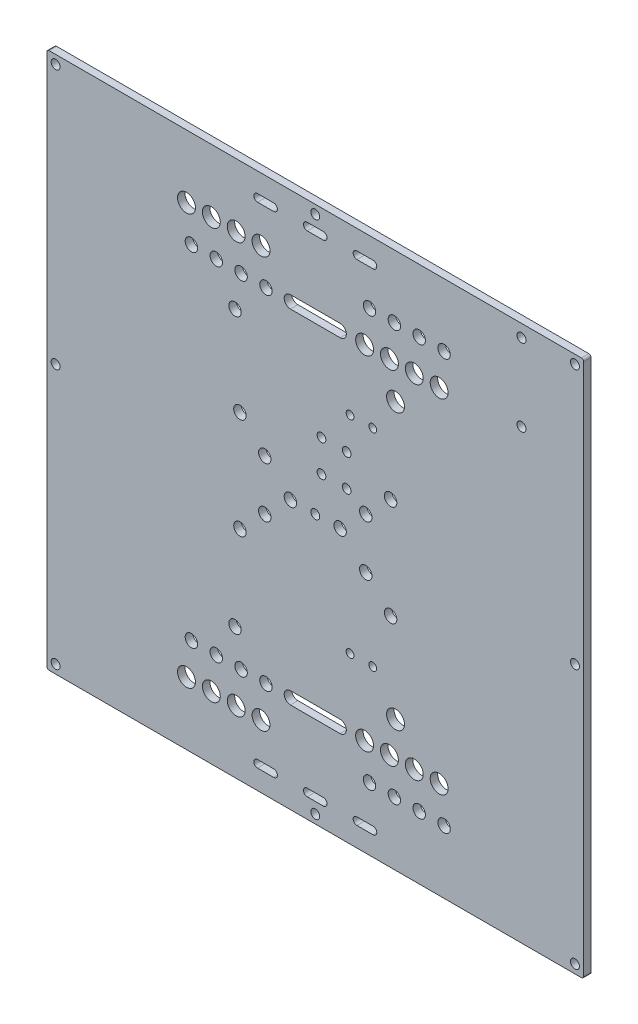
from build123d import *

# Parameters (mm, degrees)
SKETCH1_R           = 1.8
SKETCH1_R_2         = 2.5
SKETCH1_R_3         = 3.6
SKETCH1_R_4         = 1.57
SKETCH1_R_5         = 1.75
BOSS_EXTRUDE1_DEPTH = 3


with BuildPart() as part:
    # Sketch1 → Boss-Extrude1 (new body)
    with BuildSketch(Plane.XY):
        with BuildLine():
            Line((-107.125, -108), (107.125, -108))
            ThreePointArc((107.125, -108), (107.743718434, -107.743718434), (108, -107.125))
            Line((108, -107.125), (108, 107.125))
            ThreePointArc((108, 107.125), (107.743718434, 107.743718434), (107.125, 108))
            Line((107.125, 108), (-107.125, 108))
            ThreePointArc((-107.125, 108), (-107.743718434, 107.743718434), (-108, 107.125))
            Line((-108, 107.125), (-108, -107.125))
            ThreePointArc((-108, -107.125), (-107.743718434, -107.743718434), (-107.125, -108))
        make_face()
        with Locations((-104.5, -104.5)):
            Circle(SKETCH1_R, mode=Mode.SUBTRACT)
        with Locations((104.5, -104.5)):
            Circle(SKETCH1_R, mode=Mode.SUBTRACT)
        with Locations((-104.5, 104.5)):
            Circle(SKETCH1_R, mode=Mode.SUBTRACT)
        with Locations((104.5, 104.5)):
            Circle(SKETCH1_R, mode=Mode.SUBTRACT)
        with Locations((-49.85, -69)):
            Circle(SKETCH1_R_2, mode=Mode.SUBTRACT)
        with Locations((-39.85, -69)):
            Circle(SKETCH1_R_2, mode=Mode.SUBTRACT)
        with Locations((-29.85, -69)):
            Circle(SKETCH1_R_2, mode=Mode.SUBTRACT)
        with Locations((-19.855, -69)):
            Circle(SKETCH1_R_2, mode=Mode.SUBTRACT)
        with Locations((49.85, -69)):
            Circle(SKETCH1_R_3, mode=Mode.SUBTRACT)
        with Locations((39.85, -69)):
            Circle(SKETCH1_R_3, mode=Mode.SUBTRACT)
        with Locations((29.85, -69)):
            Circle(SKETCH1_R_3, mode=Mode.SUBTRACT)
        with Locations((19.855, -69)):
            Circle(SKETCH1_R_3, mode=Mode.SUBTRACT)
        with Locations((0, -104.5)):
            Circle(SKETCH1_R, mode=Mode.SUBTRACT)
        with Locations((0, 104.5)):
            Circle(SKETCH1_R, mode=Mode.SUBTRACT)
        with Locations((49.85, 69)):
            Circle(SKETCH1_R_3, mode=Mode.SUBTRACT)
        with Locations((39.85, 69)):
            Circle(SKETCH1_R_3, mode=Mode.SUBTRACT)
        with Locations((29.85, 69)):
            Circle(SKETCH1_R_3, mode=Mode.SUBTRACT)
        with Locations((19.855, 69)):
            Circle(SKETCH1_R_3, mode=Mode.SUBTRACT)
        with Locations((-19.855, 69)):
            Circle(SKETCH1_R_2, mode=Mode.SUBTRACT)
        with Locations((-29.85, 69)):
            Circle(SKETCH1_R_2, mode=Mode.SUBTRACT)
        with Locations((-39.85, 69)):
            Circle(SKETCH1_R_2, mode=Mode.SUBTRACT)
        with Locations((-49.85, 69)):
            Circle(SKETCH1_R_2, mode=Mode.SUBTRACT)
        with Locations((-104.5, 0)):
            Circle(SKETCH1_R, mode=Mode.SUBTRACT)
        with Locations((104.5, 0)):
            Circle(SKETCH1_R, mode=Mode.SUBTRACT)
        with Locations((-51.83, -82.65)):
            Circle(SKETCH1_R_3, mode=Mode.SUBTRACT)
        with Locations((-41.83, -82.65)):
            Circle(SKETCH1_R_3, mode=Mode.SUBTRACT)
        with Locations((-31.83, -82.65)):
            Circle(SKETCH1_R_3, mode=Mode.SUBTRACT)
        with Locations((-21.835, -82.65)):
            Circle(SKETCH1_R_3, mode=Mode.SUBTRACT)
        with Locations((51.83, -82.65)):
            Circle(SKETCH1_R_2, mode=Mode.SUBTRACT)
        with Locations((41.83, -82.65)):
            Circle(SKETCH1_R_2, mode=Mode.SUBTRACT)
        with Locations((31.83, -82.65)):
            Circle(SKETCH1_R_2, mode=Mode.SUBTRACT)
        with Locations((21.835, -82.65)):
            Circle(SKETCH1_R_2, mode=Mode.SUBTRACT)
        with Locations((-51.83, 82.65)):
            Circle(SKETCH1_R_3, mode=Mode.SUBTRACT)
        with Locations((-41.83, 82.65)):
            Circle(SKETCH1_R_3, mode=Mode.SUBTRACT)
        with Locations((-31.83, 82.65)):
            Circle(SKETCH1_R_3, mode=Mode.SUBTRACT)
        with Locations((-21.835, 82.65)):
            Circle(SKETCH1_R_3, mode=Mode.SUBTRACT)
        with Locations((51.83, 82.65)):
            Circle(SKETCH1_R_2, mode=Mode.SUBTRACT)
        with Locations((41.83, 82.65)):
            Circle(SKETCH1_R_2, mode=Mode.SUBTRACT)
        with Locations((31.83, 82.65)):
            Circle(SKETCH1_R_2, mode=Mode.SUBTRACT)
        with Locations((21.835, 82.65)):
            Circle(SKETCH1_R_2, mode=Mode.SUBTRACT)
        with Locations((83, 103)):
            Circle(SKETCH1_R, mode=Mode.SUBTRACT)
        with Locations((83, 72)):
            Circle(SKETCH1_R, mode=Mode.SUBTRACT)
        with Locations((-32.3, -55.35)):
            Circle(SKETCH1_R_2, mode=Mode.SUBTRACT)
        with Locations((32.3, -55.35)):
            Circle(SKETCH1_R_3, mode=Mode.SUBTRACT)
        with Locations((32.3, 55.35)):
            Circle(SKETCH1_R_3, mode=Mode.SUBTRACT)
        with Locations((-32.3, 55.35)):
            Circle(SKETCH1_R_2, mode=Mode.SUBTRACT)
        with Locations((14, -41.57)):
            Circle(SKETCH1_R_4, mode=Mode.SUBTRACT)
        with Locations((23.12, -41.57)):
            Circle(SKETCH1_R_4, mode=Mode.SUBTRACT)
        with Locations((23.12, 41.57)):
            Circle(SKETCH1_R_4, mode=Mode.SUBTRACT)
        with Locations((14, 41.57)):
            Circle(SKETCH1_R_4, mode=Mode.SUBTRACT)
        Circle(SKETCH1_R, mode=Mode.SUBTRACT)
        with Locations((-10, 0)):
            Circle(SKETCH1_R_2, mode=Mode.SUBTRACT)
        with Locations((10, 0)):
            Circle(SKETCH1_R_2, mode=Mode.SUBTRACT)
        with Locations((-20.32, 10.16)):
            Circle(SKETCH1_R_2, mode=Mode.SUBTRACT)
        with Locations((-30.32, 20.32)):
            Circle(SKETCH1_R_2, mode=Mode.SUBTRACT)
        with Locations((30.32, 20.32)):
            Circle(SKETCH1_R_2, mode=Mode.SUBTRACT)
        with Locations((20.32, 10.16)):
            Circle(SKETCH1_R_2, mode=Mode.SUBTRACT)
        with Locations((30.32, -20.32)):
            Circle(SKETCH1_R_2, mode=Mode.SUBTRACT)
        with Locations((20.32, -10.16)):
            Circle(SKETCH1_R_2, mode=Mode.SUBTRACT)
        with Locations((-20.32, -10.16)):
            Circle(SKETCH1_R_2, mode=Mode.SUBTRACT)
        with Locations((-30.32, -20.32)):
            Circle(SKETCH1_R_2, mode=Mode.SUBTRACT)
        with Locations((2.5, 28)):
            Circle(SKETCH1_R_5, mode=Mode.SUBTRACT)
        with Locations((12.64, 28)):
            Circle(SKETCH1_R_5, mode=Mode.SUBTRACT)
        with Locations((2.5, 15.17)):
            Circle(SKETCH1_R_5, mode=Mode.SUBTRACT)
        with Locations((12.64, 15.17)):
            Circle(SKETCH1_R_5, mode=Mode.SUBTRACT)
        with BuildLine():
            Line((-3.25, -97.12), (3.25, -97.12))
            ThreePointArc((3.25, -97.12), (4.75, -98.62), (3.25, -100.12))
            Line((3.25, -100.12), (-3.25, -100.12))
            ThreePointArc((-3.25, -100.12), (-4.75, -98.62), (-3.25, -97.12))
        make_face(mode=Mode.SUBTRACT)
        with BuildLine():
            Line((-23.25, -97.12), (-16.75, -97.12))
            ThreePointArc((-16.75, -97.12), (-15.25, -98.62), (-16.75, -100.12))
            Line((-16.75, -100.12), (-23.25, -100.12))
            ThreePointArc((-23.25, -100.12), (-24.75, -98.62), (-23.25, -97.12))
        make_face(mode=Mode.SUBTRACT)
        with BuildLine():
            Line((23.25, -97.12), (16.75, -97.12))
            ThreePointArc((16.75, -97.12), (15.25, -98.62), (16.75, -100.12))
            Line((16.75, -100.12), (23.25, -100.12))
            ThreePointArc((23.25, -100.12), (24.75, -98.62), (23.25, -97.12))
        make_face(mode=Mode.SUBTRACT)
        with BuildLine():
            Line((-3.25, 97.12), (3.25, 97.12))
            ThreePointArc((3.25, 97.12), (4.75, 98.62), (3.25, 100.12))
            Line((3.25, 100.12), (-3.25, 100.12))
            ThreePointArc((-3.25, 100.12), (-4.75, 98.62), (-3.25, 97.12))
        make_face(mode=Mode.SUBTRACT)
        with BuildLine():
            Line((23.25, 97.12), (16.75, 97.12))
            ThreePointArc((16.75, 97.12), (15.25, 98.62), (16.75, 100.12))
            Line((16.75, 100.12), (23.25, 100.12))
            ThreePointArc((23.25, 100.12), (24.75, 98.62), (23.25, 97.12))
        make_face(mode=Mode.SUBTRACT)
        with BuildLine():
            Line((-23.25, 97.12), (-16.75, 97.12))
            ThreePointArc((-16.75, 97.12), (-15.25, 98.62), (-16.75, 100.12))
            Line((-16.75, 100.12), (-23.25, 100.12))
            ThreePointArc((-23.25, 100.12), (-24.75, 98.62), (-23.25, 97.12))
        make_face(mode=Mode.SUBTRACT)
        with BuildLine():
            Line((-10, -66.5), (10, -66.5))
            ThreePointArc((10, -66.5), (12.5, -69), (10, -71.5))
            Line((10, -71.5), (-10, -71.5))
            ThreePointArc((-10, -71.5), (-12.5, -69), (-10, -66.5))
        make_face(mode=Mode.SUBTRACT)
        with BuildLine():
            Line((-10, 71.5), (10, 71.5))
            ThreePointArc((10, 71.5), (12.5, 69), (10, 66.5))
            Line((10, 66.5), (-10, 66.5))
            ThreePointArc((-10, 66.5), (-12.5, 69), (-10, 71.5))
        make_face(mode=Mode.SUBTRACT)
    extrude(amount=BOSS_EXTRUDE1_DEPTH)


solid = part.part
